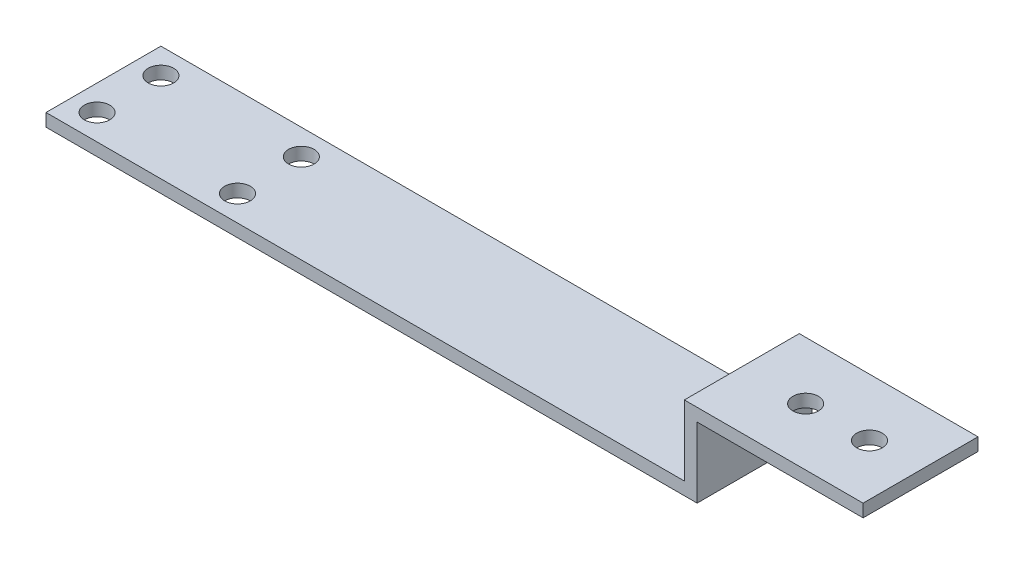
from build123d import *

# Parameters (mm, degrees)
BOSS_EXTRUDE1_DEPTH = 18
CUT_EXTRUDE1_REACH  = 4
SKETCH2_R           = 2
CUT_EXTRUDE2_REACH  = 4
SKETCH3_R           = 2


with BuildPart() as part:
    # Sketch1 → Boss-Extrude1 (new body)
    with BuildSketch(Plane.XY):
        Polygon((0, 0), (100, 0), (100, 11), (128, 11), (128, 9), (102, 9), (102, -2), (0, -2), align=None)
    extrude(amount=BOSS_EXTRUDE1_DEPTH)

    # Sketch2 → Cut-Extrude1 (cut, up to next)
    with BuildSketch(Plane(origin=(0, 0, 0), x_dir=(1, 0, 0), z_dir=(0, 1, 0)), mode=Mode.PRIVATE) as cut_extrude1_sk1:
        with Locations((4, -14)):
            Circle(SKETCH2_R)
    cut_extrude1_tool1 = extrude(cut_extrude1_sk1.sketch, amount=-CUT_EXTRUDE1_REACH, mode=Mode.PRIVATE) & part.part
    add(cut_extrude1_tool1.solids().sort_by_distance((4, 0, 14))[0], mode=Mode.SUBTRACT)
    # Sketch2 → Cut-Extrude1 (cut, up to next)
    with BuildSketch(Plane(origin=(0, 0, 0), x_dir=(1, 0, 0), z_dir=(0, 1, 0)), mode=Mode.PRIVATE) as cut_extrude1_sk2:
        with Locations((4, -4)):
            Circle(SKETCH2_R)
    cut_extrude1_tool2 = extrude(cut_extrude1_sk2.sketch, amount=-CUT_EXTRUDE1_REACH, mode=Mode.PRIVATE) & part.part
    add(cut_extrude1_tool2.solids().sort_by_distance((4, 0, 4))[0], mode=Mode.SUBTRACT)
    # Sketch2 → Cut-Extrude1 (cut, up to next)
    with BuildSketch(Plane(origin=(0, 0, 0), x_dir=(1, 0, 0), z_dir=(0, 1, 0)), mode=Mode.PRIVATE) as cut_extrude1_sk3:
        with Locations((26, -14)):
            Circle(SKETCH2_R)
    cut_extrude1_tool3 = extrude(cut_extrude1_sk3.sketch, amount=-CUT_EXTRUDE1_REACH, mode=Mode.PRIVATE) & part.part
    add(cut_extrude1_tool3.solids().sort_by_distance((26, 0, 14))[0], mode=Mode.SUBTRACT)
    # Sketch2 → Cut-Extrude1 (cut, up to next)
    with BuildSketch(Plane(origin=(0, 0, 0), x_dir=(1, 0, 0), z_dir=(0, 1, 0)), mode=Mode.PRIVATE) as cut_extrude1_sk4:
        with Locations((26, -4)):
            Circle(SKETCH2_R)
    cut_extrude1_tool4 = extrude(cut_extrude1_sk4.sketch, amount=-CUT_EXTRUDE1_REACH, mode=Mode.PRIVATE) & part.part
    add(cut_extrude1_tool4.solids().sort_by_distance((26, 0, 4))[0], mode=Mode.SUBTRACT)

    # Sketch3 → Cut-Extrude2 (cut, up to next)
    with BuildSketch(Plane.XZ.offset(-9), mode=Mode.PRIVATE) as cut_extrude2_sk1:
        with Locations((120, 9)):
            Circle(SKETCH3_R)
    cut_extrude2_tool1 = extrude(cut_extrude2_sk1.sketch, amount=-CUT_EXTRUDE2_REACH, mode=Mode.PRIVATE) & part.part
    add(cut_extrude2_tool1.solids().sort_by_distance((120, 9, 9))[0], mode=Mode.SUBTRACT)
    # Sketch3 → Cut-Extrude2 (cut, up to next)
    with BuildSketch(Plane.XZ.offset(-9), mode=Mode.PRIVATE) as cut_extrude2_sk2:
        with Locations((110, 9)):
            Circle(SKETCH3_R)
    cut_extrude2_tool2 = extrude(cut_extrude2_sk2.sketch, amount=-CUT_EXTRUDE2_REACH, mode=Mode.PRIVATE) & part.part
    add(cut_extrude2_tool2.solids().sort_by_distance((110, 9, 9))[0], mode=Mode.SUBTRACT)


solid = part.part
